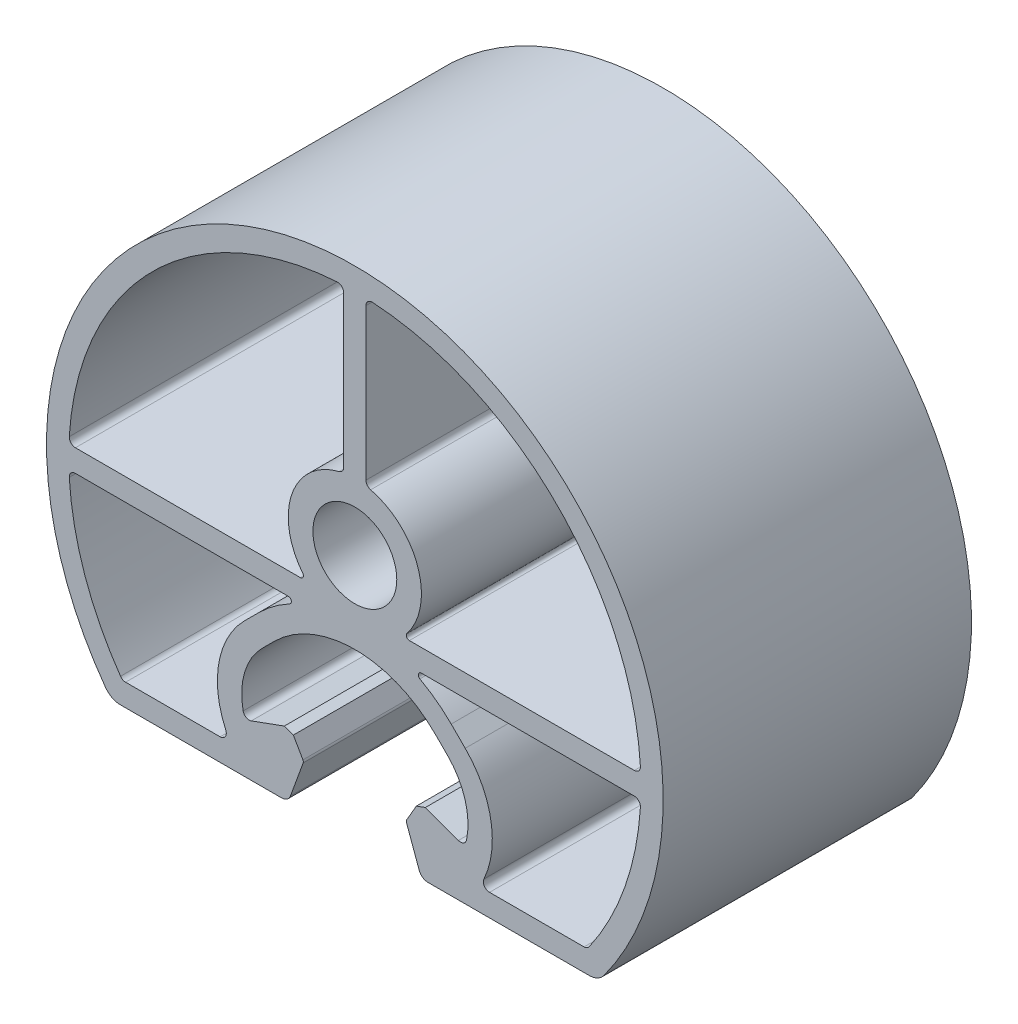
from build123d import *

# Parameters (mm, degrees)
SK_MAIN_EXTRUSION_R  = 3.4
MAIN_EXTRUSION_DEPTH = 25


with BuildPart() as part:
    # Sk Main Extrusion → Main Extrusion (new body)
    with BuildSketch(Plane.XY):
        with BuildLine():
            Line((5.926823816, -15.329316686), (19, -15.329316686))
            ThreePointArc((19, -15.329316686), (19.68041035, -15.166119497), (20.212765957, -14.712039028))
            ThreePointArc((20.212765957, -14.712039028), (0, 25), (-20.212765957, -14.712039028))
            ThreePointArc((-20.212765957, -14.712039028), (-19.68041035, -15.166119497), (-19, -15.329316686))
            Line((-19, -15.329316686), (-5.926823816, -15.329316686))
            ThreePointArc((-5.926823816, -15.329316686), (-5.496641489, -15.193680719), (-5.222054351, -14.835831793))
            Line((-5.222054351, -14.835831793), (-4.190076845, -12.000496898))
            ThreePointArc((-4.190076845, -12.000496898), (-4.175951325, -11.893202927), (-4.208493649, -11.789991862))
            Line((-4.208493649, -11.789991862), (-4.987558066, -10.44061271))
            Line((-4.987558066, -10.44061271), (-5.718509166, -10.174568267))
            Line((-5.718509166, -10.174568267), (-8.396186179, -11.149162996))
            ThreePointArc((-8.396186179, -11.149162996), (-8.811074612, -11.115806485), (-9.056960151, -10.779971153))
            ThreePointArc((-9.056960151, -10.779971153), (-8.933433013, -7.995199058), (-7.504160339, -5.602001573))
            Line((-7.504160339, -5.602001573), (-6.540737726, -4.63857896))
            ThreePointArc((-6.540737726, -4.63857896), (0, -1.929316686), (6.540737726, -4.63857896))
            Line((6.540737726, -4.63857896), (7.504160339, -5.602001573))
            ThreePointArc((7.504160339, -5.602001573), (8.933433013, -7.995199058), (9.056960151, -10.779971153))
            ThreePointArc((9.056960151, -10.779971153), (8.811074612, -11.115806485), (8.396186179, -11.149162996))
            Line((8.396186179, -11.149162996), (5.718509166, -10.174568267))
            Line((5.718509166, -10.174568267), (4.987558066, -10.44061271))
            Line((4.987558066, -10.44061271), (4.208493649, -11.789991862))
            ThreePointArc((4.208493649, -11.789991862), (4.175951325, -11.893202927), (4.190076845, -12.000496898))
            Line((4.190076845, -12.000496898), (5.222054351, -14.835831793))
            ThreePointArc((5.222054351, -14.835831793), (5.496641489, -15.193680719), (5.926823816, -15.329316686))
        make_face()
        with Locations((0, 4.670683314)):
            Circle(SK_MAIN_EXTRUSION_R, mode=Mode.SUBTRACT)
        with BuildLine():
            Line((4.418969224, 0.9), (22.656787063, 0.9))
            ThreePointArc((22.656787063, 0.9), (23.021079872, 1.05752263), (23.155835236, 1.430837004))
            ThreePointArc((23.155835236, 1.430837004), (16.404877324, 16.404877324), (1.430837004, 23.155835236))
            ThreePointArc((1.430837004, 23.155835236), (1.05752263, 23.021079872), (0.9, 22.656787063))
            Line((0.9, 22.656787063), (0.9, 10.402175266))
            ThreePointArc((0.9, 10.402175266), (1.006730351, 10.093405153), (1.281355932, 9.916455609))
            ThreePointArc((1.281355932, 9.916455609), (5.109952698, 6.416645349), (4.223439612, 1.305782448))
            ThreePointArc((4.223439612, 1.305782448), (4.193751982, 1.041477219), (4.418969224, 0.9))
        make_face(mode=Mode.SUBTRACT)
        with BuildLine():
            Line((-22.656787063, 0.9), (-4.418969224, 0.9))
            ThreePointArc((-4.418969224, 0.9), (-4.193751982, 1.041477219), (-4.223439612, 1.305782448))
            ThreePointArc((-4.223439612, 1.305782448), (-5.109952698, 6.416645349), (-1.281355932, 9.916455609))
            ThreePointArc((-1.281355932, 9.916455609), (-1.006730351, 10.093405153), (-0.9, 10.402175266))
            Line((-0.9, 10.402175266), (-0.9, 22.656787063))
            ThreePointArc((-0.9, 22.656787063), (-1.05752263, 23.021079872), (-1.430837004, 23.155835236))
            ThreePointArc((-1.430837004, 23.155835236), (-16.404877324, 16.404877324), (-23.155835236, 1.430837004))
            ThreePointArc((-23.155835236, 1.430837004), (-23.021079872, 1.05752263), (-22.656787063, 0.9))
        make_face(mode=Mode.SUBTRACT)
        with BuildLine():
            Line((-18.588354061, -13.529316686), (-10.922546302, -13.529316686))
            ThreePointArc((-10.922546302, -13.529316686), (-10.501898529, -13.299604404), (-10.467762595, -12.821538488))
            ThreePointArc((-10.467762595, -12.821538488), (-11.026944485, -8.37379017), (-8.949307842, -4.401564664))
            Line((-8.949307842, -4.401564664), (-7.813529932, -3.265786754))
            ThreePointArc((-7.813529932, -3.265786754), (-6.612567589, -2.226269195), (-5.274974996, -1.369675148))
            ThreePointArc((-5.274974996, -1.369675148), (-5.152018108, -1.088432098), (-5.394318321, -0.9))
            Line((-5.394318321, -0.9), (-22.656787063, -0.9))
            ThreePointArc((-22.656787063, -0.9), (-23.021079872, -1.05752263), (-23.155835236, -1.430837004))
            ThreePointArc((-23.155835236, -1.430837004), (-21.898586855, -7.661063488), (-18.997789172, -13.31630604))
            ThreePointArc((-18.997789172, -13.31630604), (-18.819119443, -13.472878788), (-18.588354061, -13.529316686))
        make_face(mode=Mode.SUBTRACT)
        with BuildLine():
            Line((7.813529932, -3.265786754), (8.949307842, -4.401564664))
            ThreePointArc((8.949307842, -4.401564664), (11.026944485, -8.37379017), (10.467762595, -12.821538488))
            ThreePointArc((10.467762595, -12.821538488), (10.501898529, -13.299604404), (10.922546302, -13.529316686))
            Line((10.922546302, -13.529316686), (18.588354061, -13.529316686))
            ThreePointArc((18.588354061, -13.529316686), (18.819119443, -13.472878788), (18.997789172, -13.31630604))
            ThreePointArc((18.997789172, -13.31630604), (21.898586855, -7.661063488), (23.155835236, -1.430837004))
            ThreePointArc((23.155835236, -1.430837004), (23.021079872, -1.05752263), (22.656787063, -0.9))
            Line((22.656787063, -0.9), (5.394318321, -0.9))
            ThreePointArc((5.394318321, -0.9), (5.152018108, -1.088432098), (5.274974996, -1.369675148))
            ThreePointArc((5.274974996, -1.369675148), (6.612567589, -2.226269195), (7.813529932, -3.265786754))
        make_face(mode=Mode.SUBTRACT)
    extrude(amount=-MAIN_EXTRUSION_DEPTH)


solid = part.part
